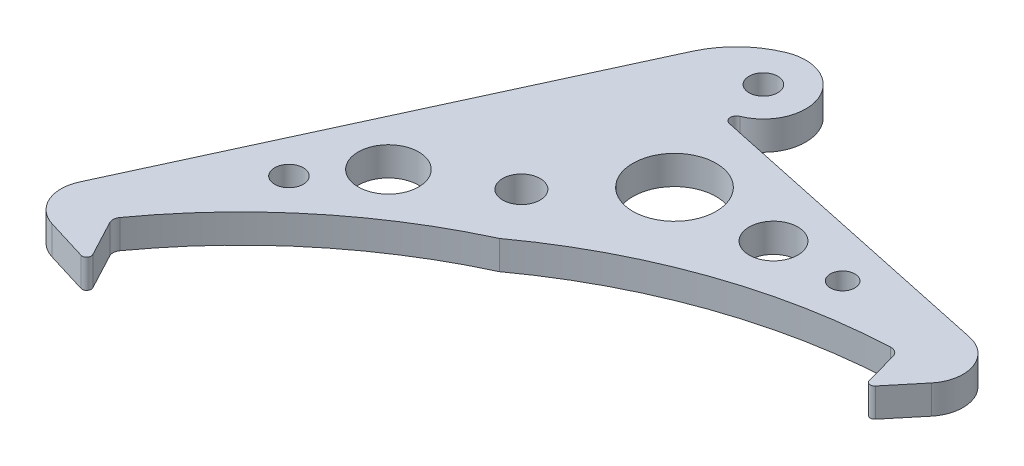
from build123d import *

# Parameters (mm, degrees)
SKETCH1_R           = 3.1
SKETCH1_R_2         = 2.375
BOSS_EXTRUDE1_DEPTH = 4.7625
FILLET1_R           = 0.75
FILLET2_R           = 1.5
CUT_EXTRUDE1_DEPTH  = 5.7625
SKETCH3_R           = 6.883378158
SKETCH3_R_2         = 4.027347077
SKETCH3_R_3         = 2.023736097
SKETCH3_R_4         = 5.007052744
SKETCH3_R_5         = 2.371370049
CUT_EXTRUDE2_DEPTH  = 5.7625


with BuildPart() as part:
    # Sketch1 → Boss-Extrude1 (new body)
    with BuildSketch(Plane(origin=(0, 0, 0), x_dir=(1, 0, 0), z_dir=(0, 1, 0))):
        with BuildLine():
            Line((-2.686438344, 87.958985039), (-0.5, 79.998437485))
            Line((-0.5, 79.998437485), (4.614887054, 86.172076174))
            ThreePointArc((4.614887054, 86.172076174), (5.661584951, 91.971127787), (1.242075777, 95.868885443))
            Line((1.242075777, 95.868885443), (-49.229512188, 106.596952642))
            ThreePointArc((-49.229512188, 106.596952642), (-50.017902784, 107.489183117), (-49.393900435, 108.503212713))
            ThreePointArc((-49.393900435, 108.503212713), (-45.503212713, 117.606099565), (-54.606099565, 121.496787287))
            ThreePointArc((-54.606099565, 121.496787287), (-59.359536161, 118.443728777), (-62.646533103, 113.84895165))
            Line((-62.646533103, 113.84895165), (-94.564318795, 44.533048109))
            ThreePointArc((-94.564318795, 44.533048109), (-94.590381999, 39.571360115), (-90.871592859, 36.28660223))
            Line((-90.871592859, 36.28660223), (-82.579358815, 33.74664323))
            Line((-82.579358815, 33.74664323), (-85.704155619, 43.38101369))
            ThreePointArc((-85.704155619, 43.38101369), (-70.503668965, 59.408545121), (-51.790728612, 71.145768882))
            ThreePointArc((-51.790728612, 71.145768882), (-28.506341212, 83.254960878), (-2.686438344, 87.958985039))
        make_face()
        with Locations((-57, 80)):
            Circle(SKETCH1_R, mode=Mode.SUBTRACT)
        with Locations((-52, 115)):
            Circle(SKETCH1_R_2, mode=Mode.SUBTRACT)
    extrude(amount=BOSS_EXTRUDE1_DEPTH)

    # Fillet1
    fillet1_edges = [part.edges().sort_by_distance(p)[0] for p in [
        (-82.579358815, 2.38125, -33.74664323),
        (-0.5, 2.38125, -79.998437485),
    ]]
    fillet(fillet1_edges, radius=FILLET1_R)

    # Fillet2
    fillet2_edges = [part.edges().sort_by_distance(p)[0] for p in [
        (-85.704155619, 2.38125, -43.38101369),
        (-2.686438344, 2.38125, -87.958985039),
    ]]
    fillet(fillet2_edges, radius=FILLET2_R)

    # Sketch2 → Cut-Extrude1 (cut, through all)
    with BuildSketch(Plane(origin=(0, 4.7625, 0), x_dir=(1, 0, 0), z_dir=(0, 1, 0))):
        with BuildLine():
            Line((-83.074868749, 35.237466844), (-86.244425002, 41.206104458))
            ThreePointArc((-86.244425002, 41.206104458), (-86.416137903, 42.011960676), (-86.136312483, 42.786936353))
            ThreePointArc((-86.136312483, 42.786936353), (-85.690987138, 43.398953447), (-85.240414354, 44.007117694))
            Line((-85.240414354, 44.007117694), (-83.023850343, 35.117099074))
            ThreePointArc((-83.023850343, 35.117099074), (-83.046731861, 35.178396715), (-83.074868749, 35.237466844))
        make_face()
    extrude(amount=-CUT_EXTRUDE1_DEPTH, mode=Mode.SUBTRACT)

    # Sketch3 → Cut-Extrude2 (cut, through all)
    with BuildSketch(Plane(origin=(0, 4.7625, 0), x_dir=(1, 0, 0), z_dir=(0, 1, 0))):
        with Locations((-44.625253906, 92.935332876)):
            Circle(SKETCH3_R)
        with Locations((-28.753871163, 93.427681096)):
            Circle(SKETCH3_R_2)
        with Locations((-17.332089479, 93.427681096)):
            Circle(SKETCH3_R_3)
        with Locations((-70.829162085, 71.852500768)):
            Circle(SKETCH3_R_4)
        with Locations((-78.10497123, 62.687125815)):
            Circle(SKETCH3_R_5)
    extrude(amount=-CUT_EXTRUDE2_DEPTH, mode=Mode.SUBTRACT)


solid = part.part
